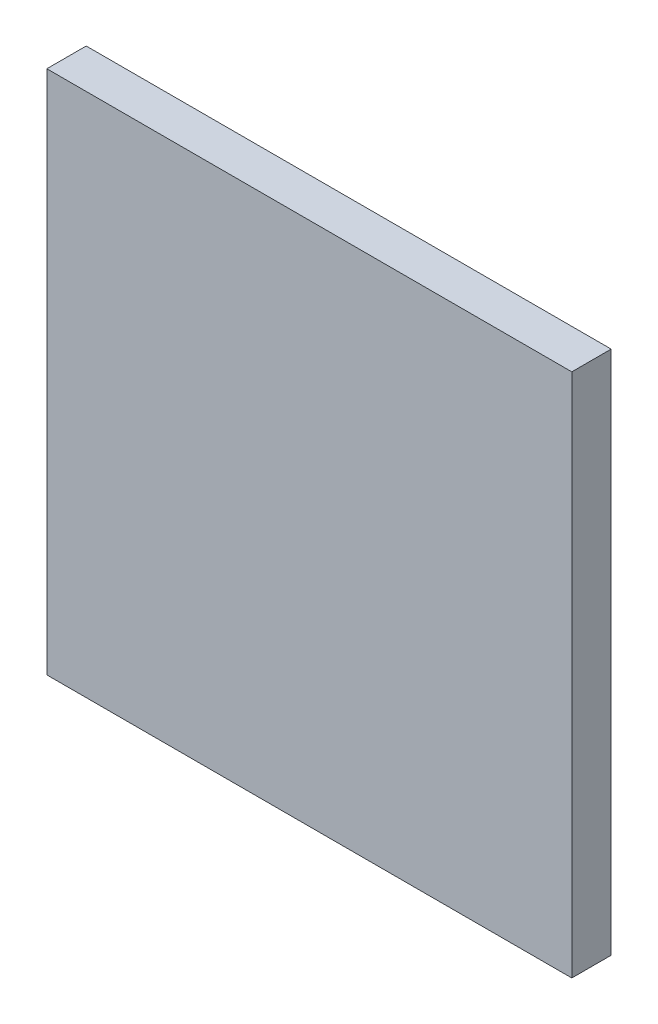
from build123d import *

# Parameters (mm, degrees)
SKETCH1_W           = 40
SKETCH1_H           = 40
BOSS_EXTRUDE1_DEPTH = 3


with BuildPart() as part:
    # Sketch1 → Boss-Extrude1 (new body)
    with BuildSketch(Plane.XY):
        Rectangle(SKETCH1_W, SKETCH1_H)
    extrude(amount=BOSS_EXTRUDE1_DEPTH)


solid = part.part
